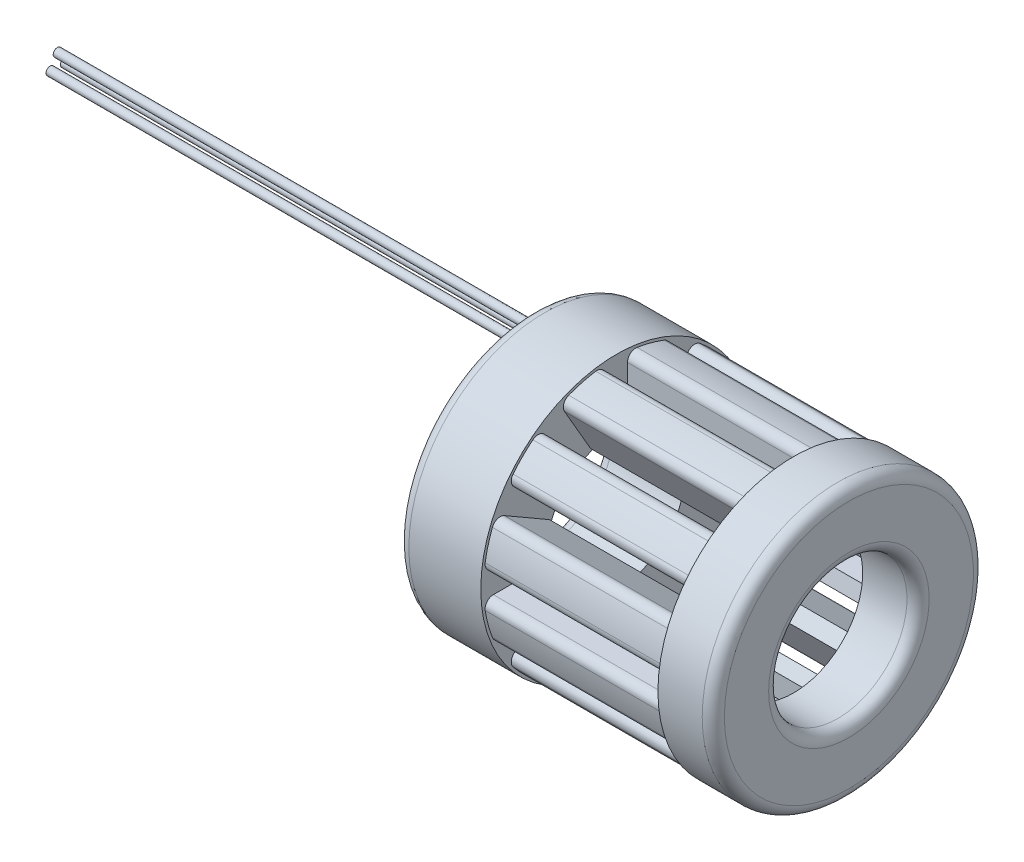
from build123d import *

# Parameters (mm, degrees)
BOSS_EXTRUDE1_START = -1
BOSS_EXTRUDE1_DEPTH = 32
CIRPATTERN3_COUNT   = 12
BOSS_EXTRUDE2_START = -2
SKETCH5_R           = 0.75
BOSS_EXTRUDE2_DEPTH = 100


with BuildPart() as part:
    # Sketch3 → Boss-Extrude1 (new body)
    with BuildSketch(Plane(origin=(0, 0, 0), x_dir=(0, 0, -1), z_dir=(1, 0, 0)).offset(BOSS_EXTRUDE1_START)):
        with BuildLine():
            Line((-2, 22.226110771), (-2, 12.821942467))
            Line((-2, 12.821942467), (-4.678920426, 12.104127903))
            Line((-4.678920426, 12.104127903), (-9.381004578, 20.248376555))
            ThreePointArc((-9.381004578, 20.248376555), (-9.496151336, 21.498457721), (-8.620764237, 22.398268325))
            ThreePointArc((-8.620764237, 22.398268325), (-6.211657082, 23.182219831), (-3.733333333, 23.707851489))
            ThreePointArc((-3.733333333, 23.707851489), (-2.525320566, 23.366286196), (-2, 22.226110771))
        make_face()
    boss_extrude1 = extrude(amount=BOSS_EXTRUDE1_DEPTH)

    # Sketch4 → Revolve1 (revolve)
    with BuildSketch(Plane.XY):
        with BuildLine():
            Line((-1, 24.5), (-14, 24.5))
            ThreePointArc((-14, 24.5), (-15.414213562, 23.914213562), (-16, 22.5))
            Line((-16, 22.5), (-16, 14.5))
            ThreePointArc((-16, 14.5), (-15.414213562, 13.085786438), (-14, 12.5))
            Line((-14, 12.5), (-1, 12.5))
            Line((-1, 12.5), (-1, 24.5))
        make_face()
        with BuildLine():
            Line((31, 24.5), (39, 24.5))
            ThreePointArc((39, 24.5), (40.414213562, 23.914213562), (41, 22.5))
            Line((41, 22.5), (41, 14.5))
            ThreePointArc((41, 14.5), (40.414213562, 13.085786438), (39, 12.5))
            Line((39, 12.5), (31, 12.5))
            Line((31, 12.5), (31, 24.5))
        make_face()
    revolve(axis=Axis((-2, 0, 0), (1, 0, 0)))

    # CirPattern3: Boss-Extrude1 ×12 about axis
    cirpattern3_axis = Axis((0, 0, 0), (1, 0, 0))
    for i in range(1, CIRPATTERN3_COUNT):
        add(boss_extrude1.rotate(cirpattern3_axis, i * 360 / CIRPATTERN3_COUNT))

    # Sketch5 → Boss-Extrude2 (add)
    with BuildSketch(Plane(origin=(0, 0, 0), x_dir=(0, 0, -1), z_dir=(1, 0, 0)).offset(BOSS_EXTRUDE2_START)):
        with Locations((-1.3, 19)):
            Circle(SKETCH5_R)
        with Locations((0, 21.25166605)):
            Circle(SKETCH5_R)
        with Locations((1.3, 19)):
            Circle(SKETCH5_R)
    extrude(amount=-BOSS_EXTRUDE2_DEPTH)


solid = part.part
